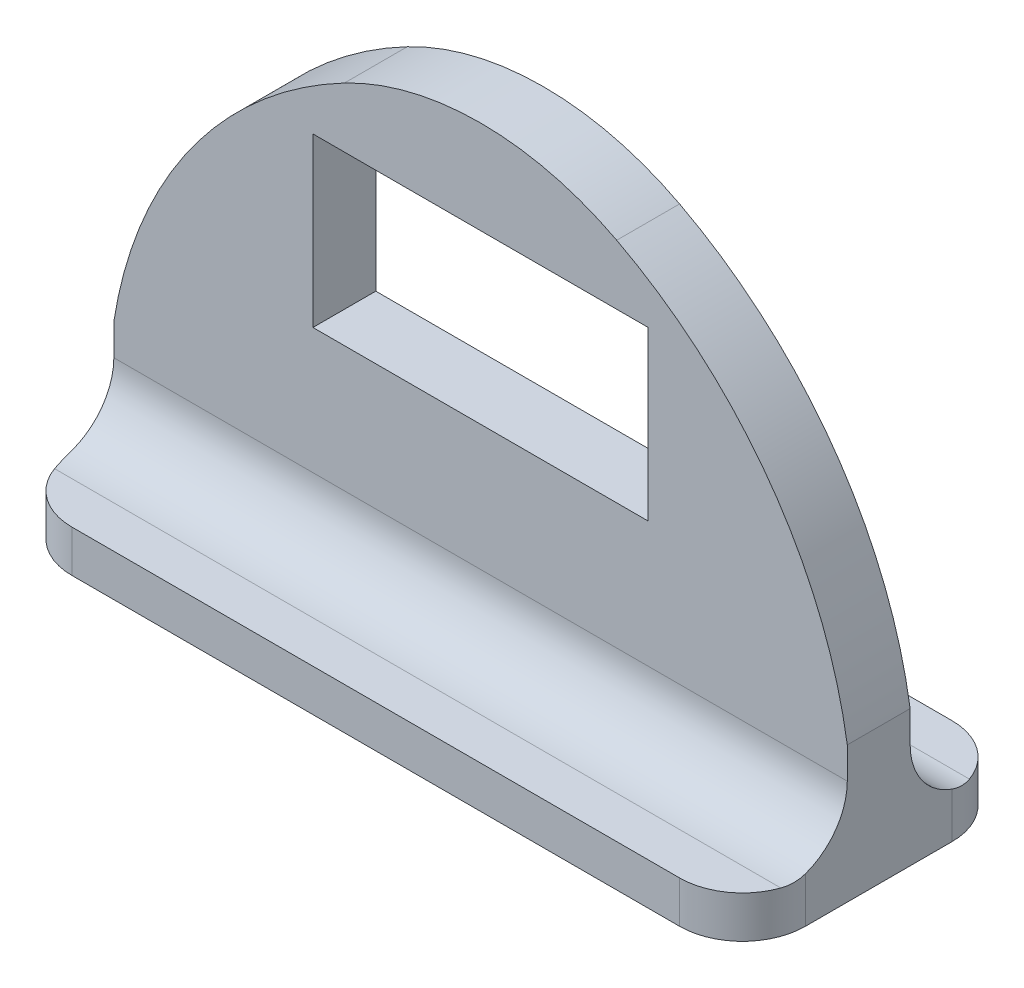
from build123d import *

# Parameters (mm, degrees)
SKETCH1_W           = 40.64
SKETCH1_H           = 20.32
BOSS_EXTRUDE1_DEPTH = 7.62
SKETCH2_W           = 88.9
SKETCH2_H           = 5.08
BOSS_EXTRUDE2_DEPTH = 12.7
SKETCH3_W           = 88.9
SKETCH3_H           = 5.08
BOSS_EXTRUDE3_DEPTH = 12.7
FILLET1_R           = 7.62
FILLET2_R           = 7.62


with BuildPart() as part:
    # Sketch1 → Boss-Extrude1 (new body)
    with BuildSketch(Plane.XY):
        with BuildLine():
            Line((-44.45, 16.51), (-44.45, 0))
            Line((-44.45, 0), (44.45, 0))
            Line((44.45, 0), (44.45, 16.51))
            ThreePointArc((44.45, 16.51), (35.108257793, 39.328942839), (16.502983922, 55.509674712))
            ThreePointArc((16.502983922, 55.509674712), (0, 59.571022016), (-16.502983922, 55.509674712))
            ThreePointArc((-16.502983922, 55.509674712), (-35.108257793, 39.328942839), (-44.45, 16.51))
        make_face()
        with Locations((0, 38.1)):
            Rectangle(SKETCH1_W, SKETCH1_H, mode=Mode.SUBTRACT)
    extrude(amount=BOSS_EXTRUDE1_DEPTH)

    # Sketch2 → Boss-Extrude2 (add)
    with BuildSketch(Plane(origin=(0, 0, 0), x_dir=(-1, 0, 0), z_dir=(0, 0, -1))):
        with Locations((0, 2.54)):
            Rectangle(SKETCH2_W, SKETCH2_H)
    extrude(amount=BOSS_EXTRUDE2_DEPTH)

    # Sketch3 → Boss-Extrude3 (add)
    with BuildSketch(Plane.XY.offset(7.62)):
        with Locations((0, 2.54)):
            Rectangle(SKETCH3_W, SKETCH3_H)
    extrude(amount=BOSS_EXTRUDE3_DEPTH)

    # Fillet1
    fillet1_edges = [part.edges().sort_by_distance(p)[0] for p in [
        (0, 5.08, 0),
        (-44.45, 2.54, 20.32),
        (44.45, 2.54, 20.32),
    ]]
    fillet(fillet1_edges, radius=FILLET1_R)

    # Fillet2
    fillet2_edges = [part.edges().sort_by_distance(p)[0] for p in [
        (-44.45, 2.54, -12.7),
        (0, 5.08, 7.62),
        (44.45, 2.54, -12.7),
    ]]
    fillet(fillet2_edges, radius=FILLET2_R)


solid = part.part
